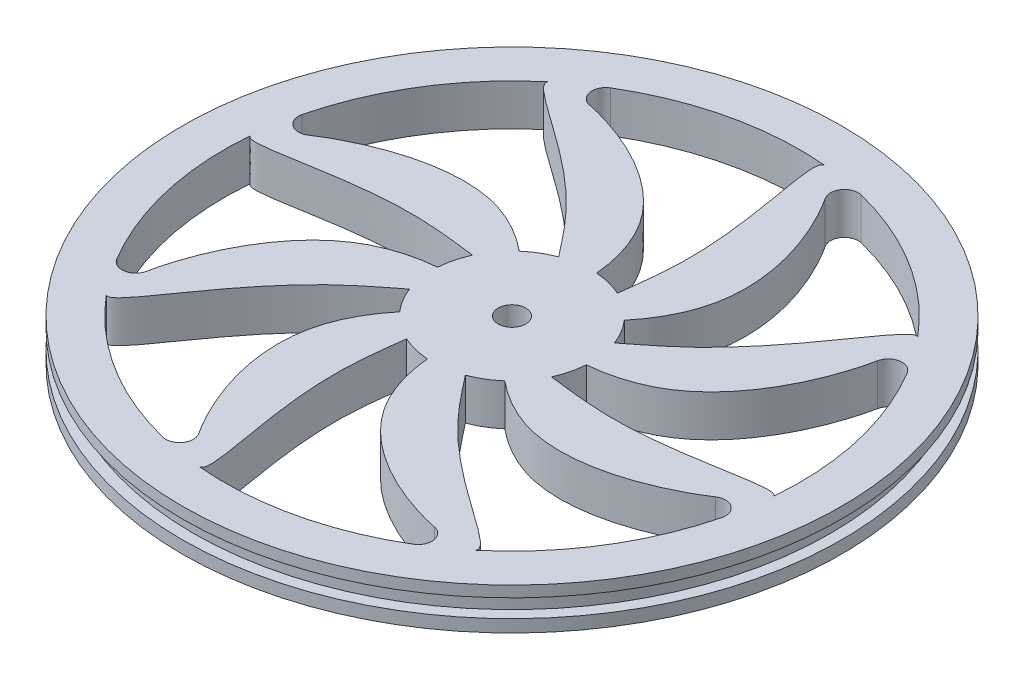
from build123d import *

# Parameters (mm, degrees)
SKETCH2_R           = 2.54
BOSS_EXTRUDE1_DEPTH = 3.81
FILLET1_R           = 2.54
FILLET2_R           = 2.54


with BuildPart() as part:
    # Sketch1 → Revolve1 (revolve)
    with BuildSketch(Plane.XY):
        Polygon((60.452, 3.81), (52.832, 3.81), (52.832, -3.81), (60.452, -3.81), (60.452, -1.524), (58.42, -1.524), (58.42, 1.778), (60.452, 1.778), align=None)
    revolve(axis=Axis((0, 57.567759105, 0), (0, -1, 0)))

    # Sketch2 → Boss-Extrude1 (add, symmetric)
    with BuildSketch(Plane(origin=(0, 0, 0), x_dir=(1, 0, 0), z_dir=(0, 1, 0))):
        with BuildLine():
            add(Edge.make_bspline(
                [(-10.967753674, -9.644397562), (-12.90186735, -11.907434426), (-23.922625676, -29.836999529), (3.868667417, -69.500387959), (-8.852161031, -33.914671292), (-6.380516634, -16.102847336), (-6.049145761, -13.293376568)],
                knots=[0.075512761, 0.075512761, 0.075512761, 0.075512761, 0.157313938, 0.525671042, 0.831994115, 0.904150252, 0.904150252, 0.904150252, 0.904150252], degree=3))
            ThreePointArc((-6.049145761, -13.293376568), (-8.701866383, -11.729601292), (-10.967753674, -9.644397562))
        make_face()
        with BuildLine():
            ThreePointArc((-10.967753674, -9.644397562), (-8.701866383, -11.729601292), (-6.049145761, -13.293376568))
            add(Edge.make_bspline(
                [(-6.049145761, -13.293376568), (-5.608964012, -9.561371567), (-5.415541442, -6.863943216), (-6.556458551, -6.556458551)],
                knots=[0.904150252, 0.904150252, 0.904150252, 0.904150252, 1, 1, 1, 1], degree=3))
            add(Edge.make_bspline(
                [(-6.556458551, -6.556458551), (-7.455300783, -6.314214658), (-9.182323805, -7.555330275), (-10.967753674, -9.644397562)],
                knots=[0, 0, 0, 0, 0.075512761, 0.075512761, 0.075512761, 0.075512761], degree=3))
        make_face()
        with BuildLine():
            add(Edge.make_bspline(
                [(-9.272232604, 0), (-9.736517742, 0.806869737), (-11.835308701, 1.150458158), (-14.574991914, 0.935754081)],
                knots=[0, 0, 0, 0, 0.075512761, 0.075512761, 0.075512761, 0.075512761], degree=3))
            ThreePointArc((-14.574991914, 0.935754081), (-14.447229342, -2.140931886), (-13.677228703, -5.122444728))
            add(Edge.make_bspline(
                [(-13.677228703, -5.122444728), (-10.72704716, -2.794774184), (-8.682906872, -1.024174717), (-9.272232604, 0)],
                knots=[0.904150252, 0.904150252, 0.904150252, 0.904150252, 1, 1, 1, 1], degree=3))
        make_face()
        with BuildLine():
            ThreePointArc((-13.677228703, -5.122444728), (-14.447229342, -2.140931886), (-14.574991914, 0.935754081))
            add(Edge.make_bspline(
                [(-14.574991914, 0.935754081), (-17.542825522, 0.703170265), (-38.013795537, -4.182093858), (-46.408634656, -51.879756586), (-30.240717146, -17.721870959), (-15.898139127, -6.874725969), (-13.677228703, -5.122444728)],
                knots=[0.075512761, 0.075512761, 0.075512761, 0.075512761, 0.157313938, 0.525671042, 0.831994115, 0.904150252, 0.904150252, 0.904150252, 0.904150252], degree=3))
        make_face()
        with BuildLine():
            add(Edge.make_bspline(
                [(-6.556458551, 6.556458551), (-6.314214658, 7.455300783), (-7.555330275, 9.182323805), (-9.644397562, 10.967753674)],
                knots=[0, 0, 0, 0, 0.075512761, 0.075512761, 0.075512761, 0.075512761], degree=3))
            ThreePointArc((-9.644397562, 10.967753674), (-11.729601292, 8.701866383), (-13.293376568, 6.049145761))
            add(Edge.make_bspline(
                [(-13.293376568, 6.049145761), (-9.561371567, 5.608964012), (-6.863943216, 5.415541442), (-6.556458551, 6.556458551)],
                knots=[0.904150252, 0.904150252, 0.904150252, 0.904150252, 1, 1, 1, 1], degree=3))
        make_face()
        with BuildLine():
            ThreePointArc((-13.293376568, 6.049145761), (-11.729601292, 8.701866383), (-9.644397562, 10.967753674))
            add(Edge.make_bspline(
                [(-9.644397562, 10.967753674), (-11.907434426, 12.90186735), (-29.836999529, 23.922625676), (-69.500387959, -3.868667417), (-33.914671292, 8.852161031), (-16.102847336, 6.380516634), (-13.293376568, 6.049145761)],
                knots=[0.075512761, 0.075512761, 0.075512761, 0.075512761, 0.157313938, 0.525671042, 0.831994115, 0.904150252, 0.904150252, 0.904150252, 0.904150252], degree=3))
        make_face()
        with BuildLine():
            add(Edge.make_bspline(
                [(0, 9.272232604), (0.806869737, 9.736517742), (1.150458158, 11.835308701), (0.935754081, 14.574991914)],
                knots=[0, 0, 0, 0, 0.075512761, 0.075512761, 0.075512761, 0.075512761], degree=3))
            ThreePointArc((0.935754081, 14.574991914), (-2.140931886, 14.447229342), (-5.122444728, 13.677228703))
            add(Edge.make_bspline(
                [(-5.122444728, 13.677228703), (-2.794774184, 10.72704716), (-1.024174717, 8.682906872), (0, 9.272232604)],
                knots=[0.904150252, 0.904150252, 0.904150252, 0.904150252, 1, 1, 1, 1], degree=3))
        make_face()
        with BuildLine():
            ThreePointArc((-5.122444728, 13.677228703), (-2.140931886, 14.447229342), (0.935754081, 14.574991914))
            add(Edge.make_bspline(
                [(0.935754081, 14.574991914), (0.703170265, 17.542825522), (-4.182093858, 38.013795537), (-51.879756586, 46.408634656), (-17.721870959, 30.240717146), (-6.874725969, 15.898139127), (-5.122444728, 13.677228703)],
                knots=[0.075512761, 0.075512761, 0.075512761, 0.075512761, 0.157313938, 0.525671042, 0.831994115, 0.904150252, 0.904150252, 0.904150252, 0.904150252], degree=3))
        make_face()
        with BuildLine():
            add(Edge.make_bspline(
                [(6.556458551, 6.556458551), (7.455300783, 6.314214658), (9.182323805, 7.555330275), (10.967753674, 9.644397562)],
                knots=[0, 0, 0, 0, 0.075512761, 0.075512761, 0.075512761, 0.075512761], degree=3))
            ThreePointArc((10.967753674, 9.644397562), (8.701866383, 11.729601292), (6.049145761, 13.293376568))
            add(Edge.make_bspline(
                [(6.049145761, 13.293376568), (5.608964012, 9.561371567), (5.415541442, 6.863943216), (6.556458551, 6.556458551)],
                knots=[0.904150252, 0.904150252, 0.904150252, 0.904150252, 1, 1, 1, 1], degree=3))
        make_face()
        with BuildLine():
            ThreePointArc((6.049145761, 13.293376568), (8.701866383, 11.729601292), (10.967753674, 9.644397562))
            add(Edge.make_bspline(
                [(10.967753674, 9.644397562), (12.90186735, 11.907434426), (23.922625676, 29.836999529), (-3.868667417, 69.500387959), (8.852161031, 33.914671292), (6.380516634, 16.102847336), (6.049145761, 13.293376568)],
                knots=[0.075512761, 0.075512761, 0.075512761, 0.075512761, 0.157313938, 0.525671042, 0.831994115, 0.904150252, 0.904150252, 0.904150252, 0.904150252], degree=3))
        make_face()
        with BuildLine():
            ThreePointArc((14.574991914, -0.935754081), (14.597496051, -0.468117556), (14.605, 0))
            ThreePointArc((14.605, 0), (14.371185585, 2.602892601), (13.677228703, 5.122444728))
            add(Edge.make_bspline(
                [(13.677228703, 5.122444728), (10.72704716, 2.794774184), (8.682906872, 1.024174717), (9.272232604, 0)],
                knots=[0.904150252, 0.904150252, 0.904150252, 0.904150252, 1, 1, 1, 1], degree=3))
            add(Edge.make_bspline(
                [(9.272232604, 0), (9.736517742, -0.806869737), (11.835308701, -1.150458158), (14.574991914, -0.935754081)],
                knots=[0, 0, 0, 0, 0.075512761, 0.075512761, 0.075512761, 0.075512761], degree=3))
        make_face()
        with BuildLine():
            ThreePointArc((13.677228703, 5.122444728), (14.371185585, 2.602892601), (14.605, 0))
            ThreePointArc((14.605, 0), (14.597496051, -0.468117556), (14.574991914, -0.935754081))
            add(Edge.make_bspline(
                [(14.574991914, -0.935754081), (17.542825522, -0.703170265), (38.013795537, 4.182093858), (46.408634656, 51.879756586), (30.240717146, 17.721870959), (15.898139127, 6.874725969), (13.677228703, 5.122444728)],
                knots=[0.075512761, 0.075512761, 0.075512761, 0.075512761, 0.157313938, 0.525671042, 0.831994115, 0.904150252, 0.904150252, 0.904150252, 0.904150252], degree=3))
        make_face()
        with BuildLine():
            add(Edge.make_bspline(
                [(9.644397562, -10.967753674), (11.907434426, -12.90186735), (29.836999529, -23.922625676), (69.500387959, 3.868667417), (33.914671292, -8.852161031), (16.102847336, -6.380516634), (13.293376568, -6.049145761)],
                knots=[0.075512761, 0.075512761, 0.075512761, 0.075512761, 0.157313938, 0.525671042, 0.831994115, 0.904150252, 0.904150252, 0.904150252, 0.904150252], degree=3))
            ThreePointArc((13.293376568, -6.049145761), (11.729601292, -8.701866383), (9.644397562, -10.967753674))
        make_face()
        with BuildLine():
            ThreePointArc((9.644397562, -10.967753674), (11.729601292, -8.701866383), (13.293376568, -6.049145761))
            add(Edge.make_bspline(
                [(13.293376568, -6.049145761), (9.561371567, -5.608964012), (6.863943216, -5.415541442), (6.556458551, -6.556458551)],
                knots=[0.904150252, 0.904150252, 0.904150252, 0.904150252, 1, 1, 1, 1], degree=3))
            add(Edge.make_bspline(
                [(6.556458551, -6.556458551), (6.314214658, -7.455300783), (7.555330275, -9.182323805), (9.644397562, -10.967753674)],
                knots=[0, 0, 0, 0, 0.075512761, 0.075512761, 0.075512761, 0.075512761], degree=3))
        make_face()
        with BuildLine():
            add(Edge.make_bspline(
                [(-0.935754081, -14.574991914), (-0.703170265, -17.542825522), (4.182093858, -38.013795537), (51.879756586, -46.408634656), (17.721870959, -30.240717146), (6.874725969, -15.898139127), (5.122444728, -13.677228703)],
                knots=[0.075512761, 0.075512761, 0.075512761, 0.075512761, 0.157313938, 0.525671042, 0.831994115, 0.904150252, 0.904150252, 0.904150252, 0.904150252], degree=3))
            ThreePointArc((5.122444728, -13.677228703), (2.140931886, -14.447229342), (-0.935754081, -14.574991914))
        make_face()
        with BuildLine():
            ThreePointArc((-0.935754081, -14.574991914), (2.140931886, -14.447229342), (5.122444728, -13.677228703))
            add(Edge.make_bspline(
                [(5.122444728, -13.677228703), (2.794774184, -10.72704716), (1.024174717, -8.682906872), (0, -9.272232604)],
                knots=[0.904150252, 0.904150252, 0.904150252, 0.904150252, 1, 1, 1, 1], degree=3))
            add(Edge.make_bspline(
                [(0, -9.272232604), (-0.806869737, -9.736517742), (-1.150458158, -11.835308701), (-0.935754081, -14.574991914)],
                knots=[0, 0, 0, 0, 0.075512761, 0.075512761, 0.075512761, 0.075512761], degree=3))
        make_face()
        with BuildLine():
            add(Edge.make_bspline(
                [(13.677228703, 5.122444728), (10.72704716, 2.794774184), (8.682906872, 1.024174717), (9.272232604, 0)],
                knots=[0.904150252, 0.904150252, 0.904150252, 0.904150252, 1, 1, 1, 1], degree=3))
            ThreePointArc((13.677228703, 5.122444728), (12.528200328, 7.506678463), (10.967753674, 9.644397562))
            add(Edge.make_bspline(
                [(6.556458551, 6.556458551), (7.455300783, 6.314214658), (9.182323805, 7.555330275), (10.967753674, 9.644397562)],
                knots=[0, 0, 0, 0, 0.075512761, 0.075512761, 0.075512761, 0.075512761], degree=3))
            add(Edge.make_bspline(
                [(6.049145761, 13.293376568), (5.608964012, 9.561371567), (5.415541442, 6.863943216), (6.556458551, 6.556458551)],
                knots=[0.904150252, 0.904150252, 0.904150252, 0.904150252, 1, 1, 1, 1], degree=3))
            ThreePointArc((6.049145761, 13.293376568), (3.550752163, 14.166798653), (0.935754081, 14.574991914))
            add(Edge.make_bspline(
                [(0, 9.272232604), (0.806869737, 9.736517742), (1.150458158, 11.835308701), (0.935754081, 14.574991914)],
                knots=[0, 0, 0, 0, 0.075512761, 0.075512761, 0.075512761, 0.075512761], degree=3))
            add(Edge.make_bspline(
                [(-5.122444728, 13.677228703), (-2.794774184, 10.72704716), (-1.024174717, 8.682906872), (0, 9.272232604)],
                knots=[0.904150252, 0.904150252, 0.904150252, 0.904150252, 1, 1, 1, 1], degree=3))
            ThreePointArc((-5.122444728, 13.677228703), (-7.506678463, 12.528200328), (-9.644397562, 10.967753674))
            add(Edge.make_bspline(
                [(-6.556458551, 6.556458551), (-6.314214658, 7.455300783), (-7.555330275, 9.182323805), (-9.644397562, 10.967753674)],
                knots=[0, 0, 0, 0, 0.075512761, 0.075512761, 0.075512761, 0.075512761], degree=3))
            add(Edge.make_bspline(
                [(-13.293376568, 6.049145761), (-9.561371567, 5.608964012), (-6.863943216, 5.415541442), (-6.556458551, 6.556458551)],
                knots=[0.904150252, 0.904150252, 0.904150252, 0.904150252, 1, 1, 1, 1], degree=3))
            ThreePointArc((-13.293376568, 6.049145761), (-14.166798653, 3.550752163), (-14.574991914, 0.935754081))
            add(Edge.make_bspline(
                [(-9.272232604, 0), (-9.736517742, 0.806869737), (-11.835308701, 1.150458158), (-14.574991914, 0.935754081)],
                knots=[0, 0, 0, 0, 0.075512761, 0.075512761, 0.075512761, 0.075512761], degree=3))
            add(Edge.make_bspline(
                [(-13.677228703, -5.122444728), (-10.72704716, -2.794774184), (-8.682906872, -1.024174717), (-9.272232604, 0)],
                knots=[0.904150252, 0.904150252, 0.904150252, 0.904150252, 1, 1, 1, 1], degree=3))
            ThreePointArc((-13.677228703, -5.122444728), (-12.528200328, -7.506678463), (-10.967753674, -9.644397562))
            add(Edge.make_bspline(
                [(-6.556458551, -6.556458551), (-7.455300783, -6.314214658), (-9.182323805, -7.555330275), (-10.967753674, -9.644397562)],
                knots=[0, 0, 0, 0, 0.075512761, 0.075512761, 0.075512761, 0.075512761], degree=3))
            add(Edge.make_bspline(
                [(-6.049145761, -13.293376568), (-5.608964012, -9.561371567), (-5.415541442, -6.863943216), (-6.556458551, -6.556458551)],
                knots=[0.904150252, 0.904150252, 0.904150252, 0.904150252, 1, 1, 1, 1], degree=3))
            ThreePointArc((-6.049145761, -13.293376568), (-3.550752163, -14.166798653), (-0.935754081, -14.574991914))
            add(Edge.make_bspline(
                [(0, -9.272232604), (-0.806869737, -9.736517742), (-1.150458158, -11.835308701), (-0.935754081, -14.574991914)],
                knots=[0, 0, 0, 0, 0.075512761, 0.075512761, 0.075512761, 0.075512761], degree=3))
            add(Edge.make_bspline(
                [(5.122444728, -13.677228703), (2.794774184, -10.72704716), (1.024174717, -8.682906872), (0, -9.272232604)],
                knots=[0.904150252, 0.904150252, 0.904150252, 0.904150252, 1, 1, 1, 1], degree=3))
            ThreePointArc((5.122444728, -13.677228703), (7.506678463, -12.528200328), (9.644397562, -10.967753674))
            add(Edge.make_bspline(
                [(6.556458551, -6.556458551), (6.314214658, -7.455300783), (7.555330275, -9.182323805), (9.644397562, -10.967753674)],
                knots=[0, 0, 0, 0, 0.075512761, 0.075512761, 0.075512761, 0.075512761], degree=3))
            add(Edge.make_bspline(
                [(13.293376568, -6.049145761), (9.561371567, -5.608964012), (6.863943216, -5.415541442), (6.556458551, -6.556458551)],
                knots=[0.904150252, 0.904150252, 0.904150252, 0.904150252, 1, 1, 1, 1], degree=3))
            ThreePointArc((13.293376568, -6.049145761), (14.166798653, -3.550752163), (14.574991914, -0.935754081))
            add(Edge.make_bspline(
                [(9.272232604, 0), (9.736517742, -0.806869737), (11.835308701, -1.150458158), (14.574991914, -0.935754081)],
                knots=[0, 0, 0, 0, 0.075512761, 0.075512761, 0.075512761, 0.075512761], degree=3))
        make_face()
        Circle(SKETCH2_R, mode=Mode.SUBTRACT)
    extrude(amount=BOSS_EXTRUDE1_DEPTH, both=True)

    # Fillet1
    fillet1_edges = [part.edges().sort_by_distance(p)[0] for p in [
        (-5.233330342, -1.9049988, 52.572164474),
    ]]
    fillet(fillet1_edges, radius=FILLET1_R)

    # Fillet2
    fillet2_edges = [part.edges().sort_by_distance(p)[0] for p in [
        (-33.473610629, -1.9049988, -40.874657375),
        (-52.572164474, 1.9049988, -5.233330342),
        (-40.874657375, 1.9049988, 33.473610629),
        (33.473610629, 1.9049988, 40.874657375),
        (52.572164474, 1.9049988, 5.233330342),
        (40.874657375, 1.9049988, -33.473610629),
        (5.233330342, 1.9049988, -52.572164474),
    ]]
    fillet(fillet2_edges, radius=FILLET2_R)


solid = part.part
